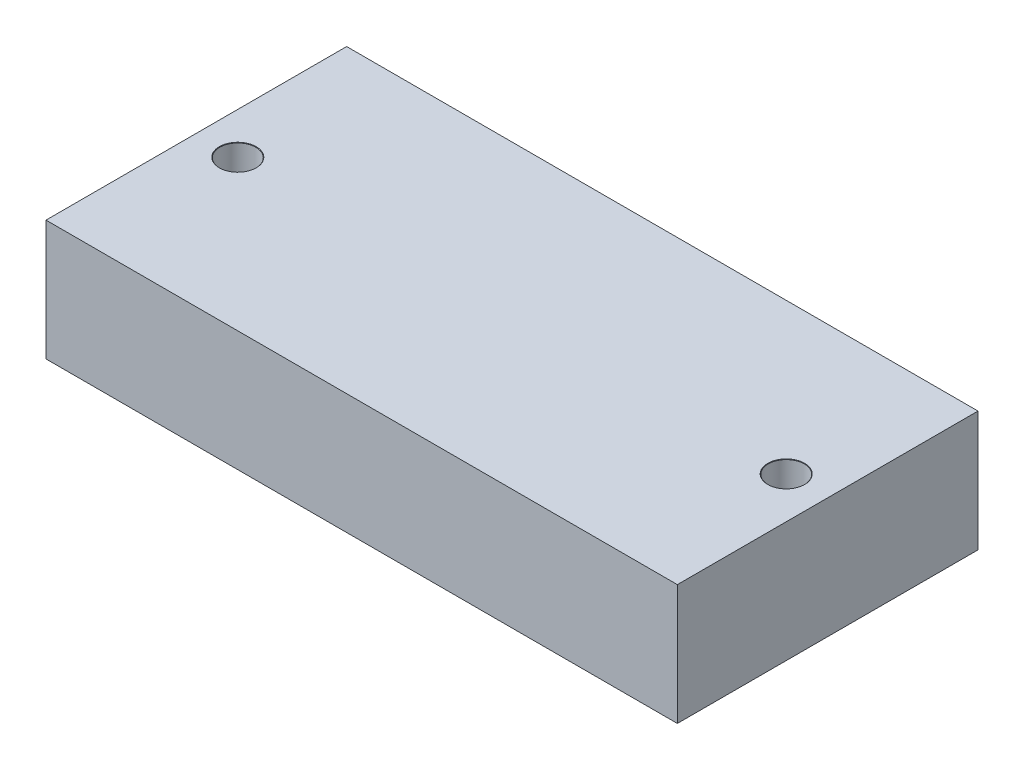
from build123d import *

# Parameters (mm, degrees)
SKETCH1_W                      = 42
SKETCH1_H                      = 20
BOSS_EXTRUDE1_DEPTH            = 8
M2_CLEARANCE_HOLE1_D           = 2.4
M2_CLEARANCE_HOLE1_CSINK_D     = 2.45
M2_CLEARANCE_HOLE1_CSINK_ANGLE = 90


with BuildPart() as part:
    # Sketch1 → Boss-Extrude1 (new body)
    with BuildSketch(Plane(origin=(0, 0, 0), x_dir=(1, 0, 0), z_dir=(0, 1, 0))):
        Rectangle(SKETCH1_W, SKETCH1_H)
    extrude(amount=BOSS_EXTRUDE1_DEPTH)

    # M2 Clearance Hole1 (through all)
    with Locations(Plane(origin=(0, 8, 0), x_dir=(1, 0, 0), z_dir=(0, 1, 0))):
        with Locations((-18.2425, 0), (18.2425, 0)):
            CounterSinkHole(M2_CLEARANCE_HOLE1_D / 2, M2_CLEARANCE_HOLE1_CSINK_D / 2, counter_sink_angle=M2_CLEARANCE_HOLE1_CSINK_ANGLE)


solid = part.part
